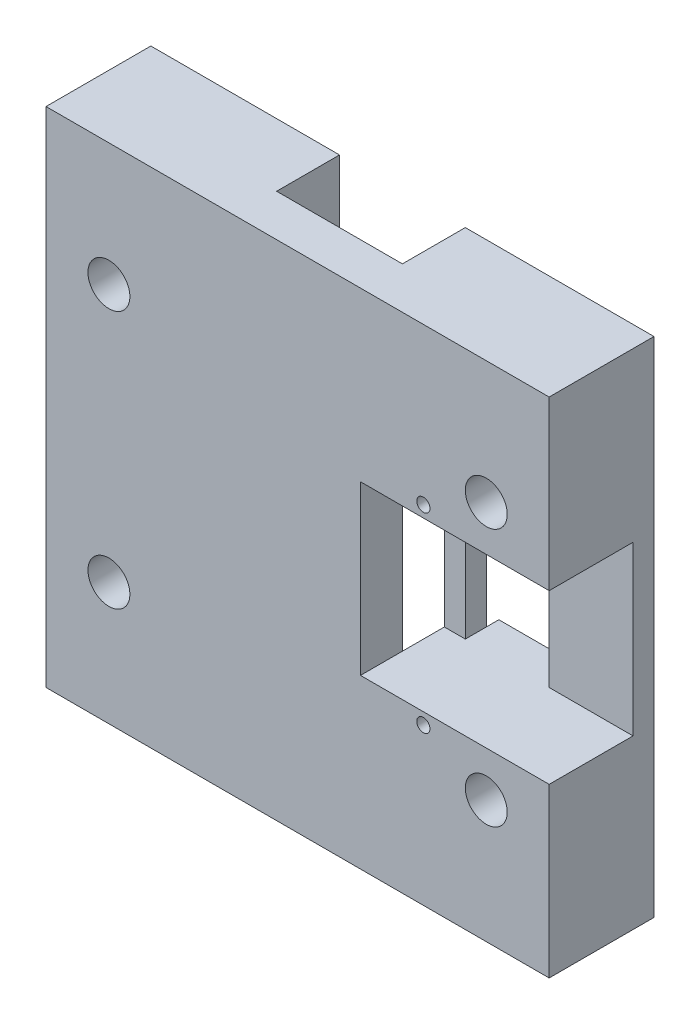
from build123d import *

# Parameters (mm, degrees)
SKETCH1_W           = 76.2
SKETCH1_H           = 76.2
SKETCH1_R           = 3.175
BOSS_EXTRUDE1_DEPTH = 6.35
SKETCH2_W           = 28.575
SKETCH2_H           = 76.2
SKETCH2_R           = 3.175
BOSS_EXTRUDE3_DEPTH = 9.525
SKETCH4_W           = 12.7
SKETCH4_H           = 25.4
CUT_EXTRUDE1_DEPTH  = 28.575
SKETCH5_W           = 12.7
SKETCH5_H           = 32.4
CUT_EXTRUDE2_DEPTH  = 9.525
SKETCH6_R           = 1
CUT_EXTRUDE3_DEPTH  = 6.35
SKETCH7_W           = 12.7
SKETCH7_H           = 3.5
SKETCH7_R           = 1
BOSS_EXTRUDE4_DEPTH = 11.43


with BuildPart() as part:
    # Sketch1 → Boss-Extrude1 (new body)
    with BuildSketch(Plane.XY):
        Rectangle(SKETCH1_W, SKETCH1_H)
        with Locations((-28.575, 19.525)):
            Circle(SKETCH1_R, mode=Mode.SUBTRACT)
        with Locations((28.575, 19.525)):
            Circle(SKETCH1_R, mode=Mode.SUBTRACT)
        with Locations((28.575, -19.525)):
            Circle(SKETCH1_R, mode=Mode.SUBTRACT)
        with Locations((-28.575, -19.525)):
            Circle(SKETCH1_R, mode=Mode.SUBTRACT)
    extrude(amount=BOSS_EXTRUDE1_DEPTH)

    # Sketch2 → Boss-Extrude3 (add)
    with BuildSketch(Plane(origin=(0, 0, 0), x_dir=(-1, 0, 0), z_dir=(0, 0, -1))):
        with Locations((-23.8125, 0)):
            Rectangle(SKETCH2_W, SKETCH2_H)
        with Locations((-28.575, -19.525)):
            Circle(SKETCH2_R, mode=Mode.SUBTRACT)
        with Locations((-28.575, 19.525)):
            Circle(SKETCH2_R, mode=Mode.SUBTRACT)
        with Locations((23.8125, 0)):
            Rectangle(SKETCH2_W, SKETCH2_H)
        with Locations((28.575, -19.525)):
            Circle(SKETCH2_R, mode=Mode.SUBTRACT)
        with Locations((28.575, 19.525)):
            Circle(SKETCH2_R, mode=Mode.SUBTRACT)
    extrude(amount=BOSS_EXTRUDE3_DEPTH)

    # Sketch4 → Cut-Extrude1 (cut)
    with BuildSketch(Plane.ZY.offset(-9.525)):
        Rectangle(SKETCH4_W, SKETCH4_H)
    extrude(amount=-CUT_EXTRUDE1_DEPTH, mode=Mode.SUBTRACT)

    # Sketch5 → Cut-Extrude2 (cut)
    with BuildSketch(Plane(origin=(0, 0, -9.525), x_dir=(-1, 0, 0), z_dir=(0, 0, -1))):
        with Locations((-19.05, 0)):
            Rectangle(SKETCH5_W, SKETCH5_H)
    extrude(amount=-CUT_EXTRUDE2_DEPTH, mode=Mode.SUBTRACT)

    # Sketch6 → Cut-Extrude3 (cut)
    with BuildSketch(Plane(origin=(0, 0, 0), x_dir=(-1, 0, 0), z_dir=(0, 0, -1))):
        with Locations((-19.05, 14.45)):
            Circle(SKETCH6_R)
        with Locations((-19.05, -14.45)):
            Circle(SKETCH6_R)
    extrude(amount=-CUT_EXTRUDE3_DEPTH, mode=Mode.SUBTRACT)

    # Sketch7 → Boss-Extrude4 (add)
    with BuildSketch(Plane(origin=(0, 0, 0), x_dir=(-1, 0, 0), z_dir=(0, 0, -1))):
        with Locations((-19.05, -14.45)):
            Rectangle(SKETCH7_W, SKETCH7_H)
        with Locations((-19.05, -14.45)):
            Circle(SKETCH7_R, mode=Mode.SUBTRACT)
        with Locations((-19.05, 14.45)):
            Rectangle(SKETCH7_W, SKETCH7_H)
        with Locations((-19.05, 14.45)):
            Circle(SKETCH7_R, mode=Mode.SUBTRACT)
    extrude(amount=BOSS_EXTRUDE4_DEPTH)


solid = part.part
